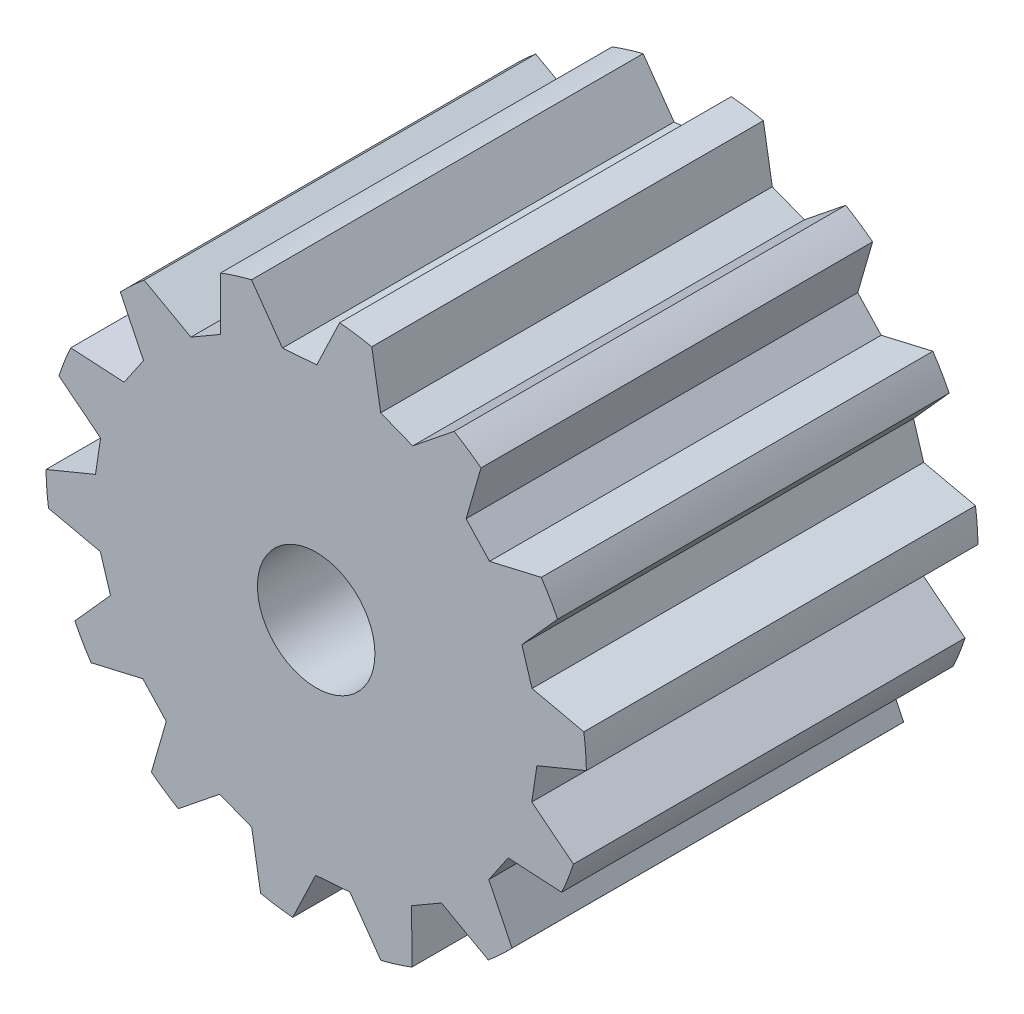
from build123d import *

# Parameters (mm, degrees)
SKETCH1_R           = 1.5
BOSS_EXTRUDE1_DEPTH = 10


with BuildPart() as part:
    # Sketch1 → Boss-Extrude1 (new body)
    with BuildSketch(Plane.XY):
        with BuildLine():
            Line((-2.438077779, 5.096888928), (-2.443359795, 6.452905773))
            ThreePointArc((-2.443359795, 6.452905773), (-2.051006224, 6.588123668), (-1.65123331, 6.699509576))
            Line((-1.65123331, 6.699509576), (-0.861593933, 5.583919403))
            Line((-0.861593933, 5.583919403), (0.01482505, 5.64998055))
            Line((0.01482505, 5.64998055), (0.598419776, 6.874001293))
            ThreePointArc((0.598419776, 6.874001293), (1.010586975, 6.825592573), (1.419098459, 6.752492841))
            Line((1.419098459, 6.752492841), (1.646502519, 5.40476914))
            Line((1.646502519, 5.40476914), (2.464791596, 5.084024232))
            Line((2.464791596, 5.084024232), (3.521674972, 5.933616552))
            ThreePointArc((3.521674972, 5.933616552), (3.87202103, 5.711169157), (4.208360374, 5.468062084))
            Line((4.208360374, 5.468062084), (3.828488954, 4.155138064))
            Line((3.828488954, 4.155138064), (4.426575937, 3.511114563))
            Line((4.426575937, 3.511114563), (5.747419249, 3.818006283))
            ThreePointArc((5.747419249, 3.818006283), (5.966553832, 3.465578648), (6.164104905, 3.100614571))
            Line((6.164104905, 3.100614571), (5.252196198, 2.082530934))
            Line((5.252196198, 2.082530934), (5.511622626, 1.242785594))
            Line((5.511622626, 1.242785594), (6.834816656, 0.946193044))
            ThreePointArc((6.834816656, 0.946193044), (6.879337474, 0.533587785), (6.898972862, 0.119052315))
            Line((6.898972862, 0.119052315), (5.635641572, -0.402546987))
            Line((5.635641572, -0.402546987), (5.505024858, -1.271692304))
            Line((5.505024858, -1.271692304), (6.568494801, -2.113025331))
            ThreePointArc((6.568494801, -2.113025331), (6.429583959, -2.504086684), (6.267414633, -2.886089711))
            Line((6.267414633, -2.886089711), (4.902879015, -2.80789554))
            Line((4.902879015, -2.80789554), (4.408089402, -3.534295945))
            Line((4.408089402, -3.534295945), (5.001201993, -4.753733125))
            ThreePointArc((5.001201993, -4.753733125), (4.706372487, -5.045796073), (4.394518071, -5.319606275))
            Line((4.394518071, -5.319606275), (3.199041139, -4.657105946))
            Line((3.199041139, -4.657105946), (2.438077779, -5.096888928))
            Line((2.438077779, -5.096888928), (2.443359795, -6.452905773))
            ThreePointArc((2.443359795, -6.452905773), (2.051006224, -6.588123668), (1.65123331, -6.699509576))
            Line((1.65123331, -6.699509576), (0.861593933, -5.583919403))
            Line((0.861593933, -5.583919403), (-0.01482505, -5.64998055))
            Line((-0.01482505, -5.64998055), (-0.598419776, -6.874001293))
            ThreePointArc((-0.598419776, -6.874001293), (-1.010586975, -6.825592573), (-1.419098459, -6.752492841))
            Line((-1.419098459, -6.752492841), (-1.646502519, -5.40476914))
            Line((-1.646502519, -5.40476914), (-2.464791596, -5.084024232))
            Line((-2.464791596, -5.084024232), (-3.521674972, -5.933616552))
            ThreePointArc((-3.521674972, -5.933616552), (-3.87202103, -5.711169157), (-4.208360374, -5.468062084))
            Line((-4.208360374, -5.468062084), (-3.828488954, -4.155138064))
            Line((-3.828488954, -4.155138064), (-4.426575937, -3.511114563))
            Line((-4.426575937, -3.511114563), (-5.747419249, -3.818006283))
            ThreePointArc((-5.747419249, -3.818006283), (-5.966553832, -3.465578648), (-6.164104905, -3.100614571))
            Line((-6.164104905, -3.100614571), (-5.252196198, -2.082530934))
            Line((-5.252196198, -2.082530934), (-5.511622626, -1.242785594))
            Line((-5.511622626, -1.242785594), (-6.834816656, -0.946193044))
            ThreePointArc((-6.834816656, -0.946193044), (-6.879337474, -0.533587785), (-6.898972862, -0.119052315))
            Line((-6.898972862, -0.119052315), (-5.635641572, 0.402546987))
            Line((-5.635641572, 0.402546987), (-5.505024858, 1.271692304))
            Line((-5.505024858, 1.271692304), (-6.568494801, 2.113025331))
            ThreePointArc((-6.568494801, 2.113025331), (-6.429583959, 2.504086684), (-6.267414633, 2.886089711))
            Line((-6.267414633, 2.886089711), (-4.902879015, 2.80789554))
            Line((-4.902879015, 2.80789554), (-4.408089402, 3.534295945))
            Line((-4.408089402, 3.534295945), (-5.001201993, 4.753733125))
            ThreePointArc((-5.001201993, 4.753733125), (-4.706372487, 5.045796073), (-4.394518071, 5.319606275))
            Line((-4.394518071, 5.319606275), (-3.199041139, 4.657105946))
            Line((-3.199041139, 4.657105946), (-2.438077779, 5.096888928))
        make_face()
        Circle(SKETCH1_R, mode=Mode.SUBTRACT)
    extrude(amount=BOSS_EXTRUDE1_DEPTH)


solid = part.part
